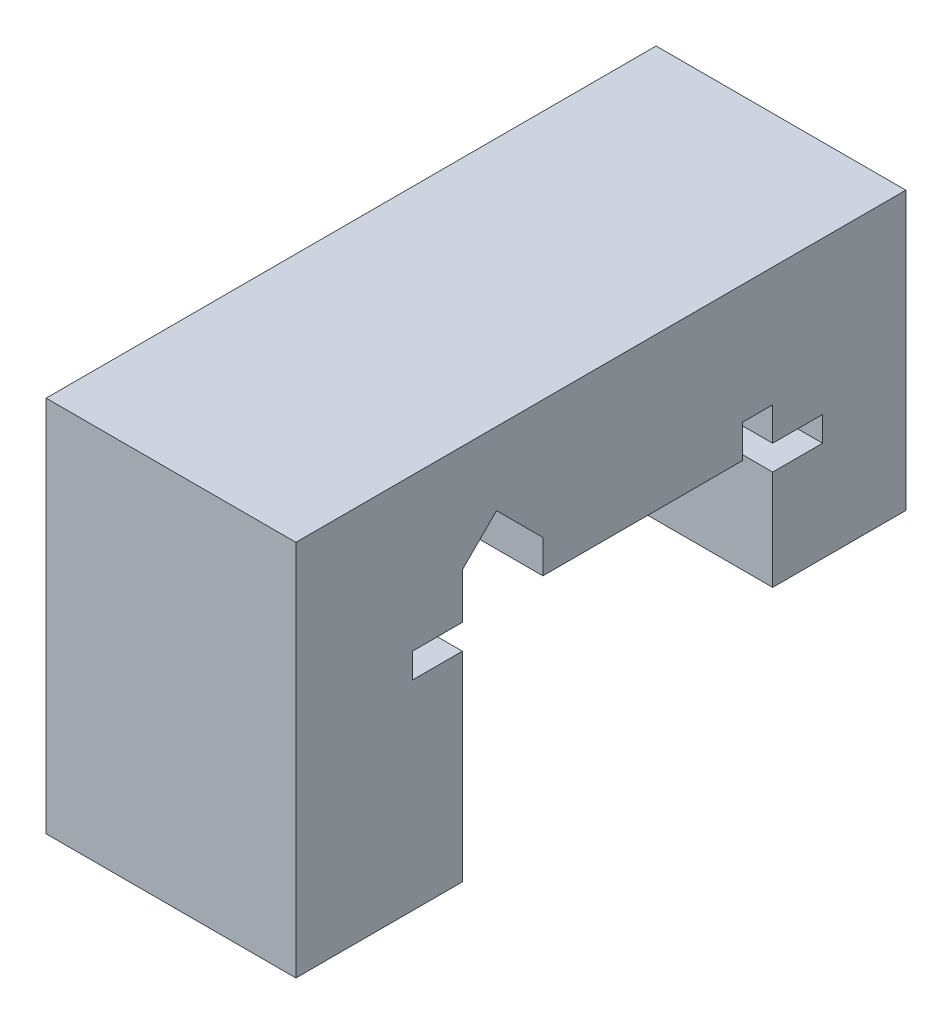
from build123d import *

# Parameters (mm, degrees)
BOSS_EXTRUDE1_DEPTH = 150


with BuildPart() as part:
    # Sketch2 → Boss-Extrude1 (new body)
    with BuildSketch(Plane(origin=(0, 0, 0), x_dir=(0, 0, -1), z_dir=(1, 0, 0))):
        Polygon((0, 0), (60, 0), (60, 20), (78.003896167, 20), (78.003896167, 0), (108.003896167, 0), (108.003896167, -15), (78.003896167, -15), (78.003896167, -75), (158.003896167, -75), (158.003896167, 91.633607591), (-208.366103833, 91.633607591), (-208.366103833, -135), (-108.366103833, -135), (-108.366103833, -15), (-138.366103833, -15), (-138.366103833, 0), (-108.366103833, 0), (-108.366103833, 27.353910524), (-87.860007179, 47.860007179), (-60, 20), (-60, 0), align=None)
    extrude(amount=BOSS_EXTRUDE1_DEPTH)


solid = part.part
